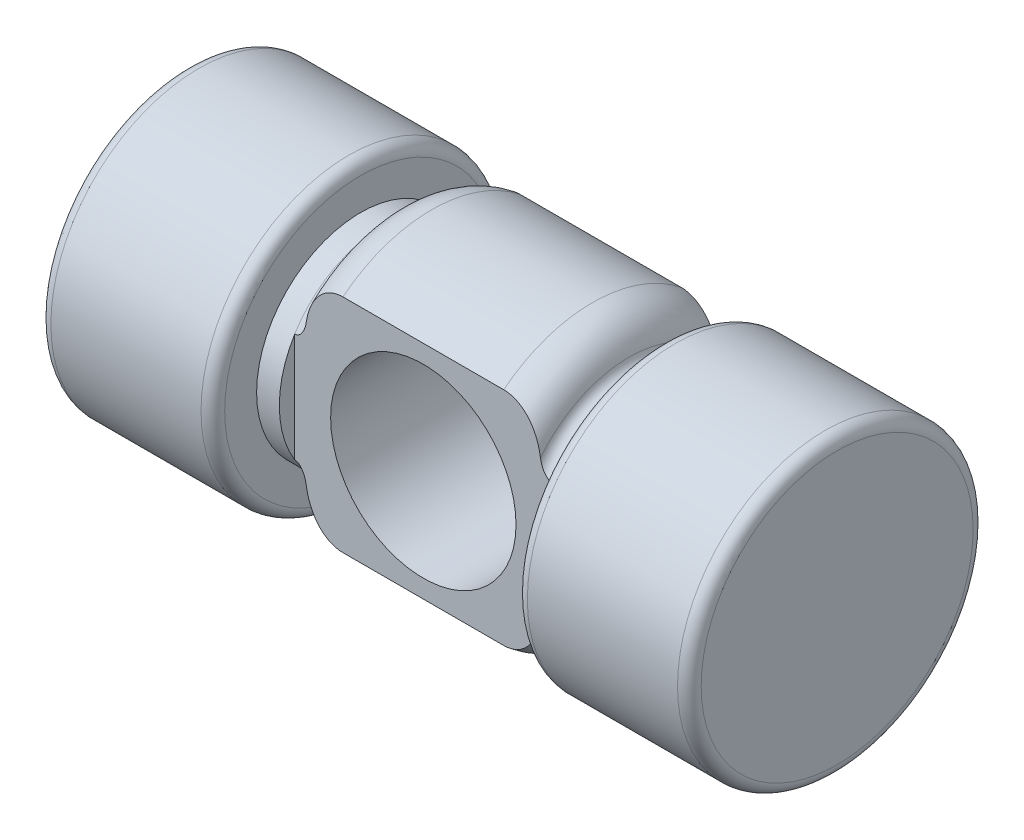
from build123d import *

# Parameters (mm, degrees)
FILLET1_R               = 0.635
SKETCH2_W               = 13.816603826
SKETCH2_H               = 21.411090548
SKETCH2_H_2             = 20.268646053
CUT_EXTRUDE1_DEPTH      = 8.9375
CUT_EXTRUDE1_DEPTH_BACK = 8.9375
SKETCH3_R               = 4.9784
CUT_EXTRUDE2_DEPTH      = 13.7000001


with BuildPart() as part:
    # Sketch1 → Revolve1 (revolve)
    with BuildSketch(Plane.XY):
        with BuildLine():
            Line((-17.4625, 0), (17.4625, 0))
            Line((17.4625, 0), (17.4625, 7.9375))
            Line((17.4625, 7.9375), (8.128, 7.9375))
            Line((8.128, 7.9375), (8.128, 5.588))
            Line((8.128, 5.588), (6.35, 5.588))
            ThreePointArc((6.35, 5.588), (5.754840979, 7.024840979), (4.318, 7.62))
            Line((4.318, 7.62), (-4.318, 7.62))
            ThreePointArc((-4.318, 7.62), (-5.754840979, 7.024840979), (-6.35, 5.588))
            Line((-6.35, 5.588), (-8.128, 5.588))
            Line((-8.128, 5.588), (-8.128, 7.9375))
            Line((-8.128, 7.9375), (-17.4625, 7.9375))
            Line((-17.4625, 7.9375), (-17.4625, 0))
        make_face()
    revolve(axis=Axis((-34.611108151, 0, 0), (1, 0, 0)))

    # Fillet1
    fillet1_edges = [part.edges().sort_by_distance(p)[0] for p in [
        (6.35, -5.588, 0),
        (8.128, -5.588, 0),
        (8.128, -7.9375, 0),
        (17.4625, -7.9375, 0),
        (-17.4625, -7.9375, 0),
        (-8.128, -7.9375, 0),
        (-6.35, -5.588, 0),
    ]]
    fillet(fillet1_edges, radius=FILLET1_R)

    # Sketch2 → Cut-Extrude1 (cut, two sides)
    with BuildSketch(Plane(origin=(0, 0, 0), x_dir=(1, 0, 0), z_dir=(0, 1, 0))) as cut_extrude1_sk:
        with Locations((0, 15.468045274)):
            Rectangle(SKETCH2_W, SKETCH2_H)
        with Locations((0, -14.896823026)):
            Rectangle(SKETCH2_W, SKETCH2_H_2)
    extrude(amount=CUT_EXTRUDE1_DEPTH, mode=Mode.SUBTRACT)
    extrude(cut_extrude1_sk.sketch, amount=-CUT_EXTRUDE1_DEPTH_BACK, mode=Mode.SUBTRACT)

    # Sketch3 → Cut-Extrude2 (cut, through all)
    with BuildSketch(Plane(origin=(0, 0, -4.7625), x_dir=(-1, 0, 0), z_dir=(0, 0, -1))):
        Circle(SKETCH3_R)
    extrude(amount=-CUT_EXTRUDE2_DEPTH, mode=Mode.SUBTRACT)


solid = part.part
